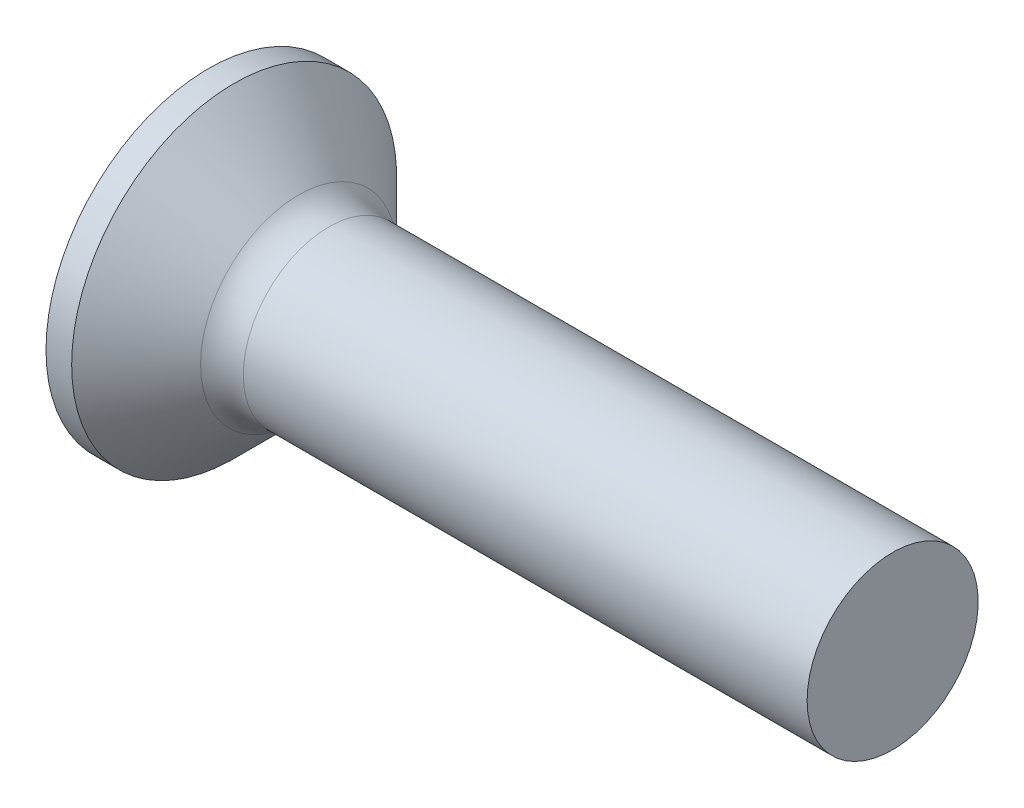
from build123d import *

# Parameters (mm, degrees)
FILLET1_R    = 0.5
SKETCH3_W    = 0.48
SKETCH3_H    = 1.9
SKETCH4_W    = 0.48
SKETCH4_H    = 0.703404182
RECPAT_COUNT = 2
RECPAT_ANGLE = 90


with BuildPart() as part:
    # BodySke → Base-Revolve (revolve)
    with BuildSketch(Plane.XY):
        Polygon((0, 0), (0, 1.9), (0.3, 1.9), (1.2, 1), (8, 1), (8, 0), align=None)
    revolve(axis=Axis((-6.35, 0, 0), (1, 0, 0)))

    # Fillet1
    fillet1_edges = [part.edges().sort_by_distance(p)[0] for p in [
        (1.2, -1, 0),
    ]]
    fillet(fillet1_edges, radius=FILLET1_R)

    # Sketch3 → Recess section 0
    with BuildSketch(Plane.ZY):
        Rectangle(SKETCH3_W, SKETCH3_H)
    # Sketch4 → Recess section 1
    with BuildSketch(Plane.ZY.offset(-1.2)):
        Rectangle(SKETCH4_W, SKETCH4_H)
    recess = loft(mode=Mode.SUBTRACT)

    # RecPat: Recess ×2 about axis
    recpat_axis = Axis((0, 0, 0), (1, 0, 0))
    for i in range(1, RECPAT_COUNT):
        add(recess.rotate(recpat_axis, i * RECPAT_ANGLE / (RECPAT_COUNT - 1)), mode=Mode.SUBTRACT)

    # RecCorSke → RecessCore (revolve, cut)
    with BuildSketch(Plane.XY):
        Polygon((0, 0), (0, 0.439412174), (1.2, 0.3555), (1.315508952, 0), align=None)
    revolve(axis=Axis((-3.175, 0, 0), (1, 0, 0)), mode=Mode.SUBTRACT)


solid = part.part
